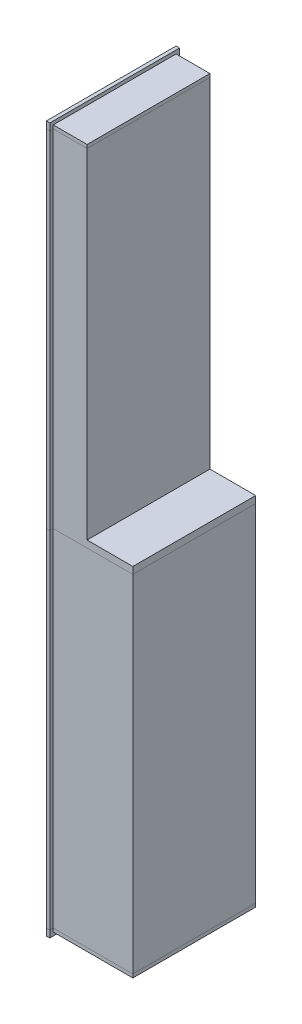
from build123d import *

# Parameters (mm, degrees)
BOSS_EXTRU_1_DEPTH      = 200
BOSS_EXTRU_2_DEPTH      = 200
ESQUISSE4_W             = 26.442514416
ESQUISSE4_H             = 71
BOSS_EXTRU_3_DEPTH      = 4
BOSS_EXTRU_5_DEPTH      = 4
ESQUISSE6_W             = 46
ESQUISSE6_H             = 71
ENL_V_MAT_EXTRU_1_DEPTH = 2
ESQUISSE7_W             = 26.442514416
ESQUISSE7_H             = 71
ENL_V_MAT_EXTRU_2_DEPTH = 5
ESQUISSE8_R             = 12.5
BOSS_EXTRU_6_DEPTH      = 400
ESQUISSE10_W            = 25
ESQUISSE10_H            = 200
ENL_V_MAT_EXTRU_3_DEPTH = 35.5


with BuildPart() as part:
    # Esquisse1 → Boss.-Extru.1 (new body)
    with BuildSketch(Plane(origin=(0, 0, 0), x_dir=(1, 0, 0), z_dir=(0, 1, 0))):
        with BuildLine():
            Line((-46, -35.5), (-17, -35.5))
            Line((-17, -35.5), (0, -35.5))
            Line((0, -35.5), (0, 35.5))
            Line((0, 35.5), (-46, 35.5))
            Line((-46, 35.5), (-46, 37.5))
            Line((-46, 37.5), (-48, 37.5))
            Line((-48, 37.5), (-48, 33.5))
            Line((-48, 33.5), (-17, 33.5))
            ThreePointArc((-17, 33.5), (-6.393398282, 29.106601718), (-2, 18.5))
            Line((-2, 18.5), (-2, -18.5))
            ThreePointArc((-2, -18.5), (-6.393398282, -29.106601718), (-17, -33.5))
            Line((-17, -33.5), (-48, -33.5))
            Line((-48, -33.5), (-48, -37.5))
            Line((-48, -37.5), (-46, -37.5))
            Line((-46, -37.5), (-46, -35.5))
        make_face()
    extrude(amount=BOSS_EXTRU_1_DEPTH)


with BuildPart() as body_2:
    # Esquisse2 → Boss.-Extru.2 (new body)
    with BuildSketch(Plane.XZ.offset(-200)):
        Polygon((-46, 37.5), (-48, 37.5), (-48, -8.5), (-34.5, -8.5), (-34.5, -33.5), (-48, -33.5), (-48, -37.5), (-46, -37.5), (-46, -35.5), (-26.442514416, -35.5), (-26.442514416, 35.5), (-46, 35.5), align=None)
    extrude(amount=-BOSS_EXTRU_2_DEPTH)

    # Esquisse4 → Boss.-Extru.3 (add)
    with BuildSketch(Plane.XZ.offset(-200)):
        with Locations((-13.221257208, 0)):
            Rectangle(ESQUISSE4_W, ESQUISSE4_H)
    extrude(amount=-BOSS_EXTRU_3_DEPTH)


with BuildPart() as body_3:
    # Esquisse5 → Boss.-Extru.5 (new body)
    with BuildSketch(Plane.XZ):
        Polygon((-48, -37.5), (-48, 37.5), (-46, 37.5), (-46, 35.5), (0, 35.5), (0, -35.5), (-46, -35.5), (-46, -37.5), align=None)
    extrude(amount=BOSS_EXTRU_5_DEPTH)

    # Esquisse6 → Enl_v. mat.-Extru.1 (cut)
    with BuildSketch(Plane.XZ.offset(4)):
        with Locations((-23, 0)):
            Rectangle(ESQUISSE6_W, ESQUISSE6_H)
    extrude(amount=-ENL_V_MAT_EXTRU_1_DEPTH, mode=Mode.SUBTRACT)


with BuildPart() as body_4:
    # Sym_trie1: mirrored copy
    add(body_3.part.mirror(Plane(origin=(0, 200, 0), x_dir=(0, 0, 1), z_dir=(0, -1, 0))))

    # Esquisse7 → Enl_v. mat.-Extru.2 (cut, through all)
    with BuildSketch(Plane.XZ.offset(-400)):
        with Locations((-13.221257208, 0)):
            Rectangle(ESQUISSE7_W, ESQUISSE7_H)
    extrude(amount=-ENL_V_MAT_EXTRU_2_DEPTH, mode=Mode.SUBTRACT)


with BuildPart() as body_5:
    # Esquisse8 → Boss.-Extru.6 (new body)
    with BuildSketch(Plane.XZ.offset(-400)):
        with Locations(Location((-34.5, -21, 0), (0, 0, 270))):  # turned: the seam where the file's is
            Circle(ESQUISSE8_R)
    extrude(amount=BOSS_EXTRU_6_DEPTH)

    # Esquisse10 → Enl_v. mat.-Extru.3 (cut, through all)
    with BuildSketch(Plane.ZY.offset(34.5)):
        with Locations((-21, 300)):
            Rectangle(ESQUISSE10_W, ESQUISSE10_H)
    extrude(amount=-ENL_V_MAT_EXTRU_3_DEPTH, mode=Mode.SUBTRACT)


solid = Compound([part.part, body_2.part, body_3.part, body_4.part, body_5.part])
